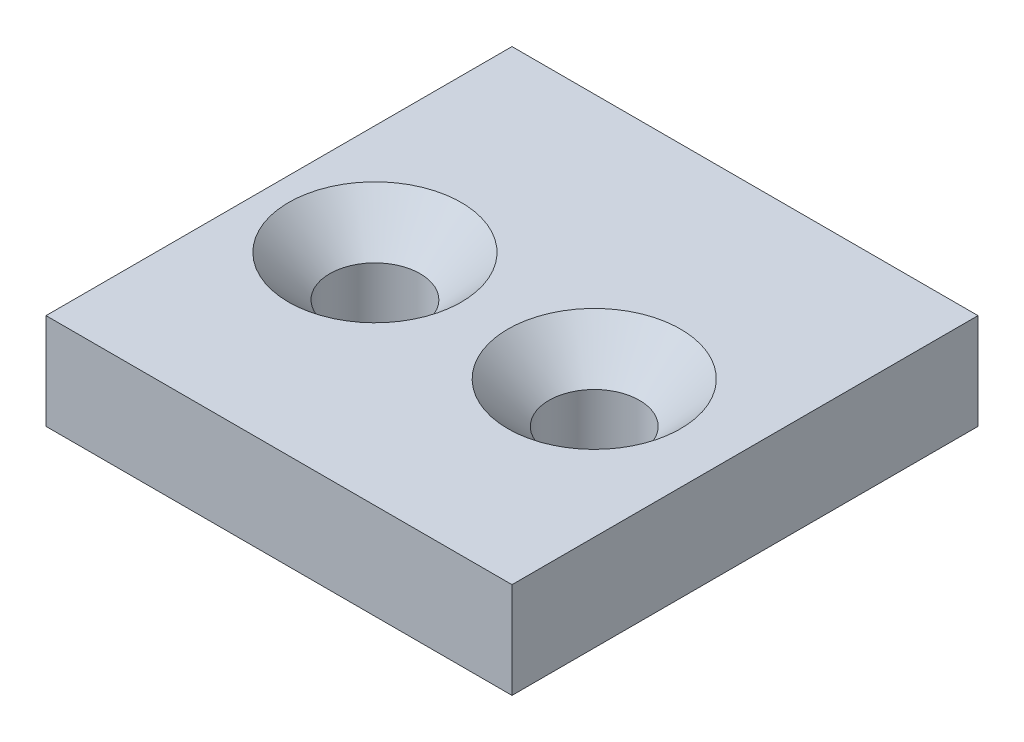
from build123d import *

# Parameters (mm, degrees)
SKETCH3_W                                       = 34
SKETCH3_H                                       = 34
BOSS_EXTRUDE2_DEPTH                             = 7
CSK_FOR_M6_FLAT_HEAD_MACHINE_SCREW1_D           = 6.6
CSK_FOR_M6_FLAT_HEAD_MACHINE_SCREW1_CSINK_D     = 12.6
CSK_FOR_M6_FLAT_HEAD_MACHINE_SCREW1_CSINK_ANGLE = 90


with BuildPart() as part:
    # Sketch3 → Boss-Extrude2 (new body)
    with BuildSketch(Plane(origin=(0, 0, 0), x_dir=(1, 0, 0), z_dir=(0, 1, 0))):
        with Locations((17, 17)):
            Rectangle(SKETCH3_W, SKETCH3_H)
    extrude(amount=BOSS_EXTRUDE2_DEPTH)

    # CSK for M6 Flat Head Machine Screw1 (through all)
    with Locations(Plane(origin=(0, 7, 0), x_dir=(1, 0, 0), z_dir=(0, 1, 0))):
        with Locations((8, 16), (24, 16)):
            CounterSinkHole(CSK_FOR_M6_FLAT_HEAD_MACHINE_SCREW1_D / 2, CSK_FOR_M6_FLAT_HEAD_MACHINE_SCREW1_CSINK_D / 2, counter_sink_angle=CSK_FOR_M6_FLAT_HEAD_MACHINE_SCREW1_CSINK_ANGLE)


solid = part.part
